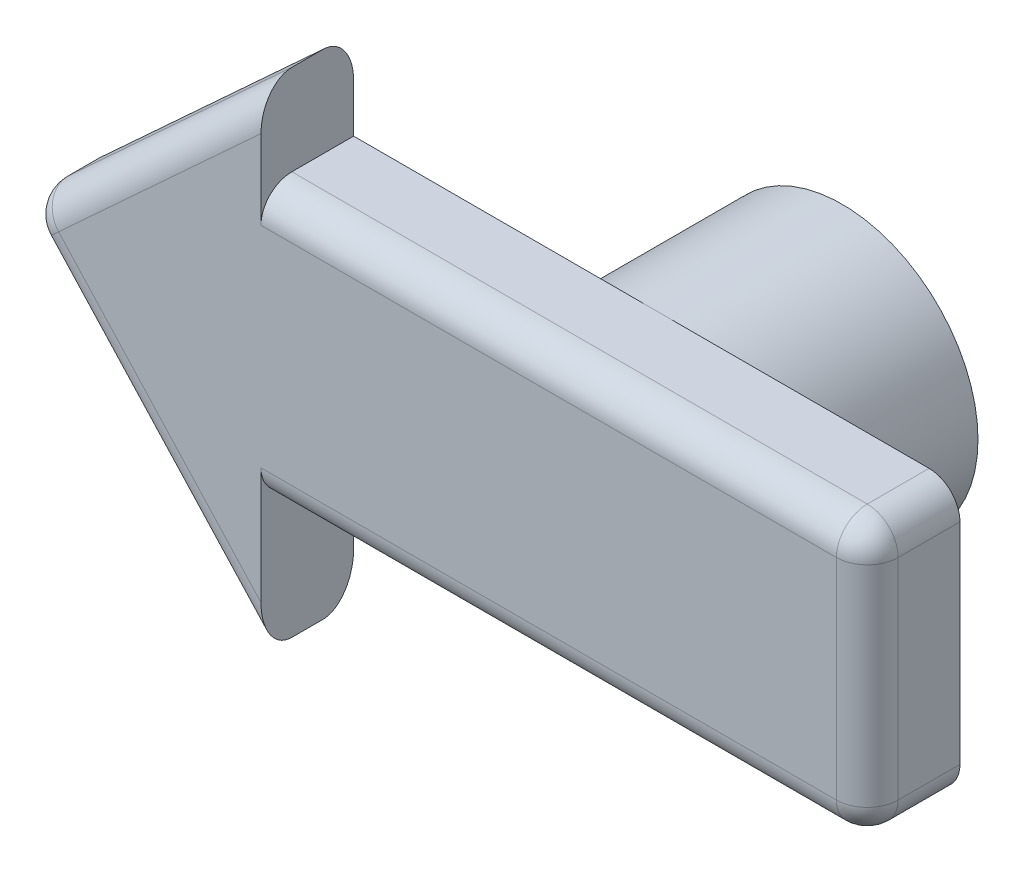
from build123d import *

# Parameters (mm, degrees)
SKETCH1_R           = 4.4
SKETCH1_R_2         = 3.1
BOSS_EXTRUDE1_DEPTH = 6
BOSS_EXTRUDE2_DEPTH = 3
FILLET1_R           = 1


with BuildPart() as part:
    # Sketch1 → Boss-Extrude1 (new body)
    with BuildSketch(Plane.XY):
        with Locations((0, -3.7)):
            Circle(SKETCH1_R)
        with Locations((0, -3.7)):
            Circle(SKETCH1_R_2, mode=Mode.SUBTRACT)
    extrude(amount=-BOSS_EXTRUDE1_DEPTH)

    # Sketch2 → Boss-Extrude2 (add)
    with BuildSketch(Plane.XY):
        Polygon((9.815203288, -8.1), (9.815203288, 0.7), (-9.815203288, 0.7), (-9.815203288, 3.629197365), (-17.779678307, -3.7), (-9.815203288, -12.354817051), (-9.815203288, -8.1), align=None)
    extrude(amount=BOSS_EXTRUDE2_DEPTH)

    # Fillet1
    fillet1_edges = [part.edges().sort_by_distance(p)[0] for p in [
        (-13.797440798, -8.027408526, 0),
        (-17.779678307, -3.7, 1.5),
        (9.815203288, -8.1, 1.5),
        (9.815203288, 0.7, 1.5),
        (-13.797440798, -0.035401317, 0),
        (-13.797440798, -8.027408526, 3),
        (0, -8.1, 3),
        (9.815203288, -3.7, 3),
        (0, 0.7, 3),
        (-13.797440798, -0.035401317, 3),
    ]]
    fillet(fillet1_edges, radius=FILLET1_R)


solid = part.part
